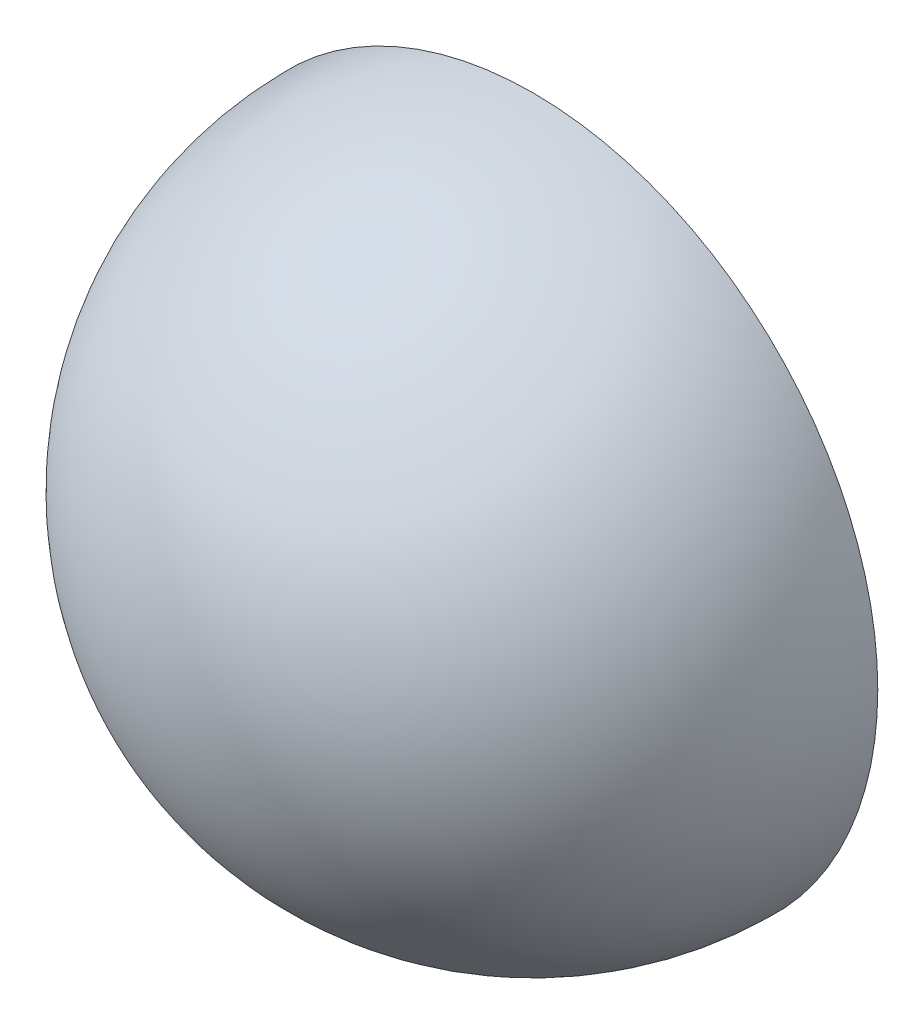
from build123d import *


with BuildPart() as part:
    # Sketch1 → Revolve1 (revolve)
    with BuildSketch(Plane(origin=(0, 0, 0), x_dir=(1, 0, 0), z_dir=(0, 1, 0))):
        with BuildLine():
            Line((-2.5, 0), (0, 0))
            Line((0, 0), (0, -2.5))
            ThreePointArc((0, -2.5), (-1.767766953, -1.767766953), (-2.5, 0))
        make_face()
    revolve(axis=Axis((0, 0, 2.5), (0, 0, -1)))


solid = part.part
